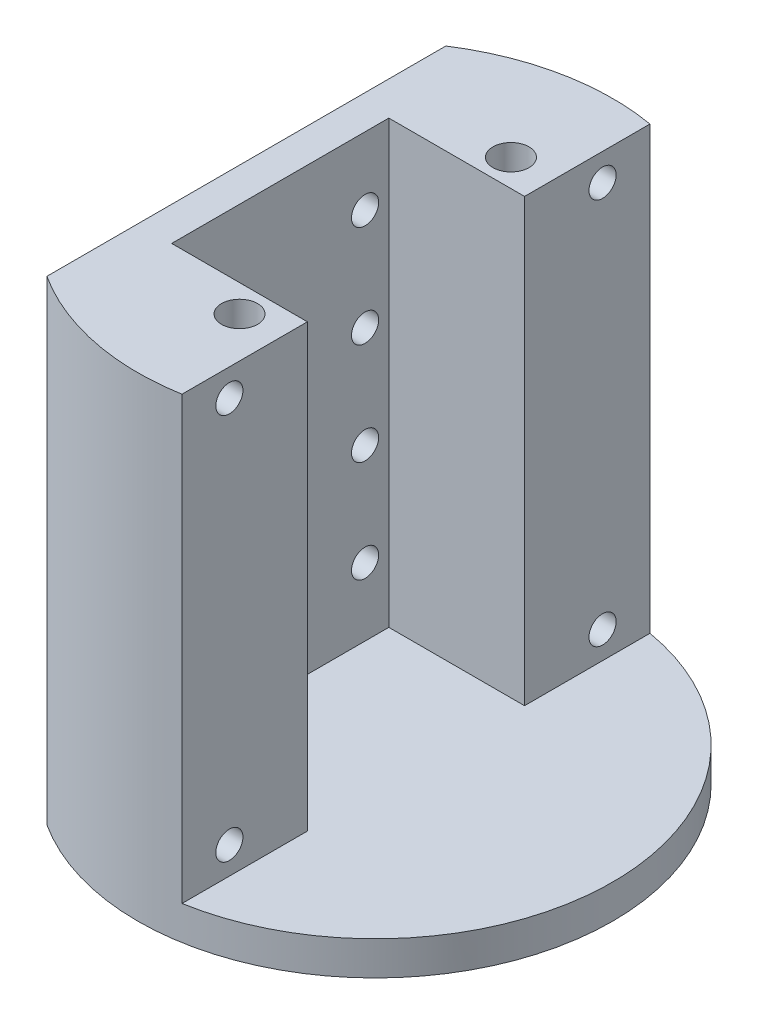
from build123d import *

# Parameters (mm, degrees)
BOSS_EXTRUDE1_DEPTH     = 88.9
SKETCH2_R               = 2.54
CUT_EXTRUDE1_DEPTH      = 4.445
F_1_4_CLEARANCE_HOLE1_D = 6.7564
BOSS_EXTRUDE3_DEPTH     = 6.35
SKETCH8_R               = 2.54
CUT_EXTRUDE2_DEPTH      = 4.445


with BuildPart() as part:
    # Sketch1 → Boss-Extrude1 (new body)
    with BuildSketch(Plane(origin=(0, 0, 0), x_dir=(1, 0, 0), z_dir=(0, 1, 0))):
        with BuildLine():
            Line((-17.78, 20.32), (7.62, 20.32))
            Line((7.62, 20.32), (7.62, 43.79198671))
            ThreePointArc((7.62, 43.79198671), (-8.864740287, 43.557076114), (-24.13, 37.33022368))
            Line((-24.13, 37.33022368), (-24.13, -37.33022368))
            ThreePointArc((-24.13, -37.33022368), (-8.864740287, -43.557076114), (7.62, -43.79198671))
            Line((7.62, -43.79198671), (7.62, -20.32))
            Line((7.62, -20.32), (-17.78, -20.32))
            Line((-17.78, -20.32), (-17.78, 20.32))
        make_face()
    extrude(amount=BOSS_EXTRUDE1_DEPTH)

    # Sketch2 → Cut-Extrude1 (cut)
    with BuildSketch(Plane(origin=(-17.78, 0, 0), x_dir=(0, 0, -1), z_dir=(1, 0, 0))):
        with Locations((-15.875, 76.2)):
            Circle(SKETCH2_R)
        with Locations((15.875, 76.2)):
            Circle(SKETCH2_R)
        with Locations((-15.875, 57.15)):
            Circle(SKETCH2_R)
        with Locations((15.875, 57.15)):
            Circle(SKETCH2_R)
        with Locations((-15.875, 38.1)):
            Circle(SKETCH2_R)
        with Locations((15.875, 38.1)):
            Circle(SKETCH2_R)
        with Locations((-15.875, 19.05)):
            Circle(SKETCH2_R)
        with Locations((15.875, 19.05)):
            Circle(SKETCH2_R)
    extrude(amount=-CUT_EXTRUDE1_DEPTH, mode=Mode.SUBTRACT)

    # 1/4 Clearance Hole1 (through all)
    with Locations(Plane(origin=(0, 88.9, 0), x_dir=(1, 0, 0), z_dir=(0, 1, 0))):
        with Locations((0, -25.4), (0, 25.4)):
            Hole(F_1_4_CLEARANCE_HOLE1_D / 2)

    # Sketch7 → Boss-Extrude3 (add)
    with BuildSketch(Plane.XZ):
        with BuildLine():
            Line((7.62, -20.32), (7.62, -43.79198671))
            ThreePointArc((7.62, -43.79198671), (44.45, 0), (7.62, 43.79198671))
            Line((7.62, 43.79198671), (7.62, 20.32))
            Line((7.62, 20.32), (-17.78, 20.32))
            Line((-17.78, 20.32), (-17.78, -20.32))
            Line((-17.78, -20.32), (7.62, -20.32))
        make_face()
    extrude(amount=-BOSS_EXTRUDE3_DEPTH)

    # Sketch8 → Cut-Extrude2 (cut)
    with BuildSketch(Plane(origin=(7.62, 0, 0), x_dir=(0, 0, -1), z_dir=(1, 0, 0))):
        with Locations((-34.925, 83.82)):
            Circle(SKETCH8_R)
        with Locations((34.925, 83.82)):
            Circle(SKETCH8_R)
        with Locations((-34.925, 11.43)):
            Circle(SKETCH8_R)
        with Locations((34.925, 11.43)):
            Circle(SKETCH8_R)
    extrude(amount=-CUT_EXTRUDE2_DEPTH, mode=Mode.SUBTRACT)


solid = part.part
